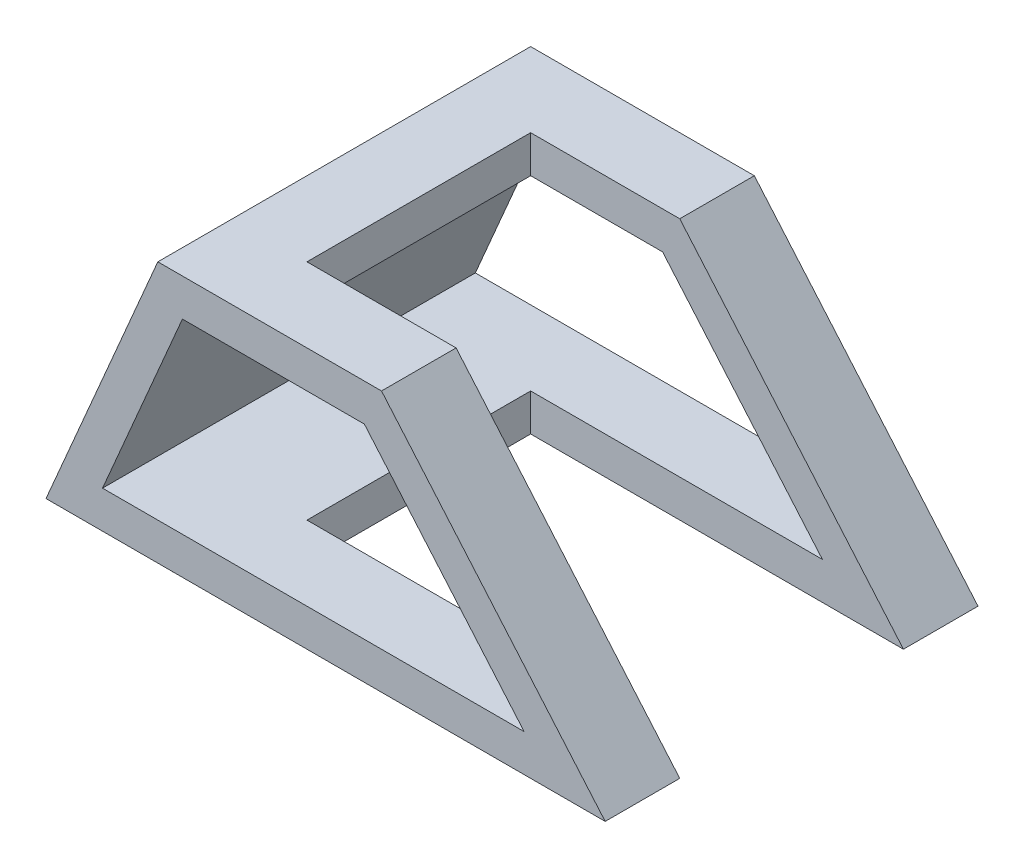
from build123d import *

# Parameters (mm, degrees)
BOSS_EXTRU_1_DEPTH      = 50
ENL_V_MAT_EXTRU_1_DEPTH = 30


with BuildPart() as part:
    # Esquisse3 → Boss.-Extru.1 (new, symmetric)
    with BuildSketch(Plane.XY):
        Polygon((30, 70), (0, 0), (150, 0), (90, 70), align=None)
        Polygon((36.59396158, 60), (85.400650775, 60), (128.257793632, 10), (15.165390151, 10), align=None, mode=Mode.SUBTRACT)
    extrude(amount=BOSS_EXTRU_1_DEPTH, both=True)

    # Esquisse3_3 → Enl_v. mat.-Extru.1 (cut, symmetric)
    with BuildSketch(Plane.XY):
        Polygon((50, 10), (50, 0), (150, 0), (90, 70), (50, 70), (50, 60), (85.400650775, 60), (128.257793632, 10), align=None)
    extrude(amount=ENL_V_MAT_EXTRU_1_DEPTH, both=True, mode=Mode.SUBTRACT)


solid = part.part
